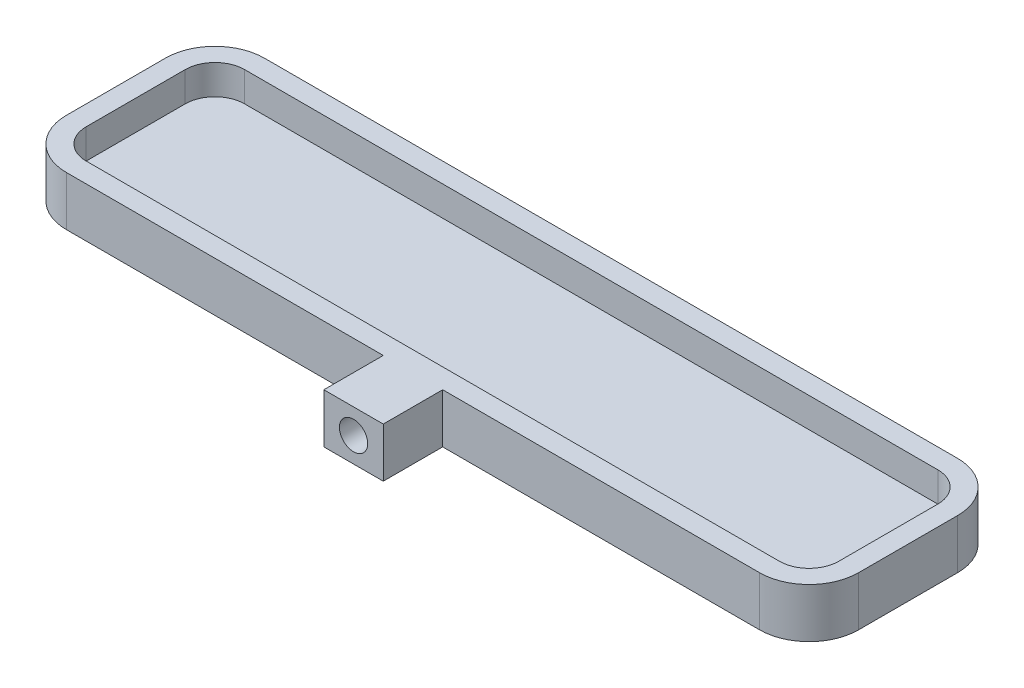
from build123d import *

# Parameters (mm, degrees)
SKETCH1_W           = 80
SKETCH1_H           = 20
BOSS_EXTRUDE1_DEPTH = 5
FILLET1_R           = 5
SHELL1_T            = -2
SKETCH2_W           = 6
SKETCH2_H           = 5
BOSS_EXTRUDE2_DEPTH = 6
SKETCH3_R           = 1.425
CUT_EXTRUDE1_DEPTH  = 4


with BuildPart() as part:
    # Sketch1 → Boss-Extrude1 (new body)
    with BuildSketch(Plane(origin=(0, 0, 0), x_dir=(1, 0, 0), z_dir=(0, 1, 0))):
        Rectangle(SKETCH1_W, SKETCH1_H)
    extrude(amount=BOSS_EXTRUDE1_DEPTH)

    # Fillet1
    fillet1_edges = [part.edges().sort_by_distance(p)[0] for p in [
        (40, 2.5, 10),
        (-40, 2.5, 10),
        (-40, 2.5, -10),
        (40, 2.5, -10),
    ]]
    fillet(fillet1_edges, radius=FILLET1_R)

    # Shell1
    shell1_openings = [part.faces().sort_by_distance(p)[0] for p in [
        (0, 5, 0),
    ]]
    offset(amount=SHELL1_T, openings=shell1_openings, kind=Kind.INTERSECTION)

    # Sketch2 → Boss-Extrude2 (add)
    with BuildSketch(Plane.XY.offset(10)):
        with Locations((0, 2.5)):
            Rectangle(SKETCH2_W, SKETCH2_H)
    extrude(amount=BOSS_EXTRUDE2_DEPTH)

    # Sketch3 → Cut-Extrude1 (cut)
    with BuildSketch(Plane.XY.offset(16)):
        with Locations((0, 2.5)):
            Circle(SKETCH3_R)
    extrude(amount=-CUT_EXTRUDE1_DEPTH, mode=Mode.SUBTRACT)


solid = part.part
